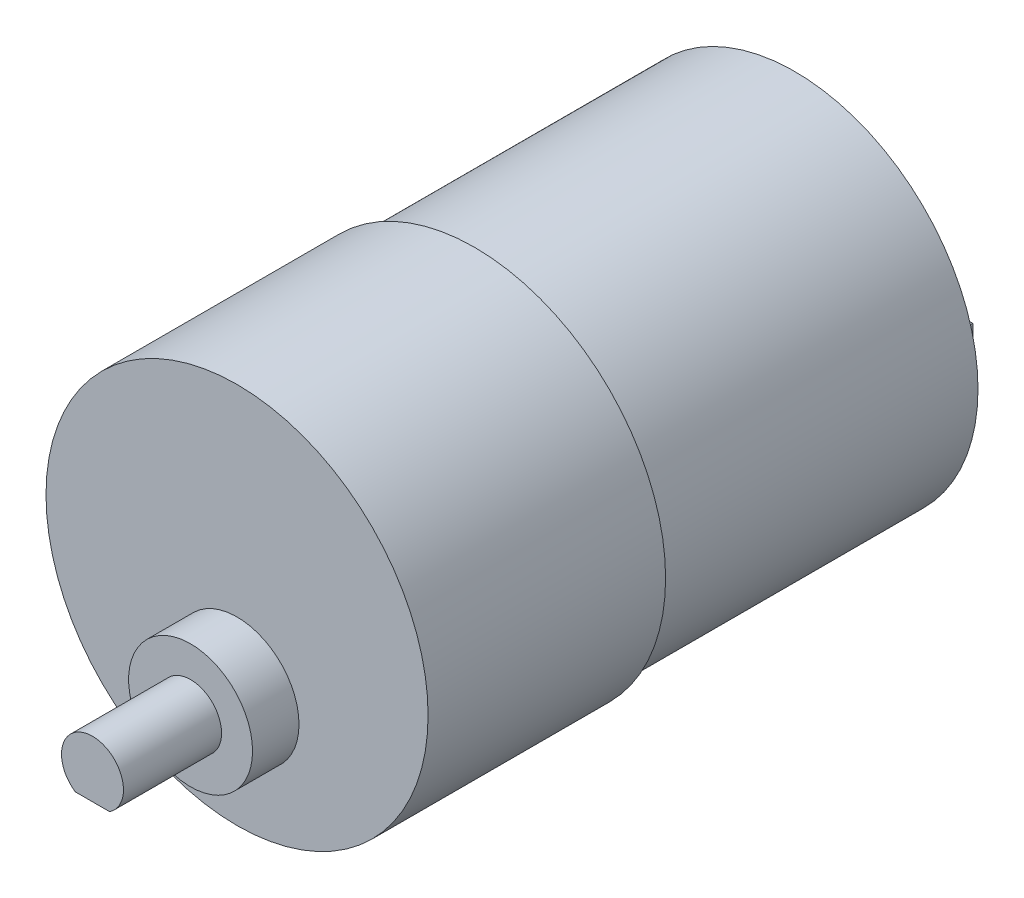
from build123d import *

# Parameters (mm, degrees)
SKETCH3_W           = 1.5
SKETCH3_H           = 2.5
BOSS_EXTRUDE1_DEPTH = 4
SKETCH4_R           = 6
BOSS_EXTRUDE2_DEPTH = 4.5
BOSS_EXTRUDE3_DEPTH = 14


with BuildPart() as part:
    # Sketch2 → Revolve1 (revolve)
    with BuildSketch(Plane(origin=(0, 0, 0), x_dir=(1, 0, 0), z_dir=(0, 1, 0))):
        Polygon((0, -54), (0, 0), (17.75, 0), (17.75, -31), (18.5, -31), (18.5, -54), align=None)
    revolve(axis=Axis((0, 0, 54), (0, 0, -1)))

    # Sketch3 → Boss-Extrude1 (add)
    with BuildSketch(Plane(origin=(0, 0, 0), x_dir=(-1, 0, 0), z_dir=(0, 0, -1))):
        with Locations((-12.5, 0)):
            Rectangle(SKETCH3_W, SKETCH3_H)
        with Locations((12.5, 0)):
            Rectangle(SKETCH3_W, SKETCH3_H)
    extrude(amount=BOSS_EXTRUDE1_DEPTH)

    # Sketch4 → Boss-Extrude2 (add)
    with BuildSketch(Plane.XY.offset(54)):
        with Locations((0, -7)):
            Circle(SKETCH4_R)
        with BuildLine():
            Line((-1.658312395, -9.5), (1.658312395, -9.5))
            ThreePointArc((1.658312395, -9.5), (0, -4), (-1.658312395, -9.5))
        make_face(mode=Mode.SUBTRACT)
    extrude(amount=BOSS_EXTRUDE2_DEPTH)

    # Sketch4_2 → Boss-Extrude3 (add)
    with BuildSketch(Plane.XY.offset(54)):
        with BuildLine():
            ThreePointArc((1.658312395, -9.5), (0, -4), (-1.658312395, -9.5))
            Line((-1.658312395, -9.5), (1.658312395, -9.5))
        make_face()
    extrude(amount=BOSS_EXTRUDE3_DEPTH)


solid = part.part
